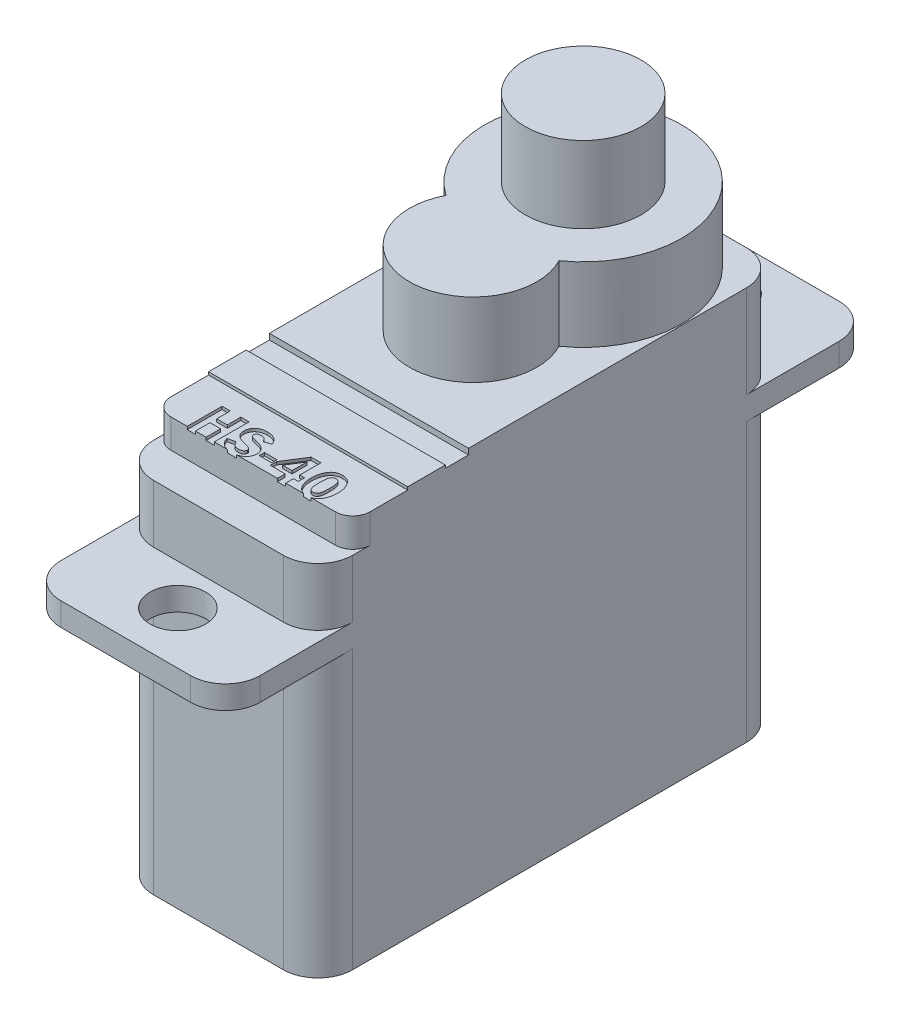
from build123d import *

# Parameters (mm, degrees)
SKETCH1_W            = 8.6
SKETCH1_H            = 28
BOSS_EXTRUDE1_DEPTH  = 1
SKETCH2_W            = 8.6
SKETCH2_H            = 20
BOSS_EXTRUDE2_DEPTH  = 4
M2_CLEARANCE_HOLE1_D = 2.4
SKETCH6_R            = 4.25
BOSS_EXTRUDE3_DEPTH  = 3.2
SKETCH7_R            = 2.5
BOSS_EXTRUDE4_DEPTH  = 3.3
SKETCH8_W            = 8.6
SKETCH8_H            = 20
BOSS_EXTRUDE5_DEPTH  = 12
SKETCH9_R            = 2.75
BOSS_EXTRUDE6_DEPTH  = 3.2
FILLET1_R            = 1.5
SKETCH10_W           = 8.6
SKETCH10_H           = 1.5
CUT_EXTRUDE1_DEPTH   = 1.5
FILLET2_R            = 0.75
SKETCH11_W           = 8.6
SKETCH11_H           = 5
CUT_EXTRUDE2_DEPTH   = 0.125
SKETCH12_W           = 8.6
SKETCH12_H           = 1
CUT_EXTRUDE3_DEPTH   = 0.125
SKETCH13_W           = 8.6
SKETCH13_H           = 2.375
CUT_EXTRUDE4_DEPTH   = 0.125
SKETCH14_W           = 0.541666667
SKETCH14_H           = 0.229166667
CUT_EXTRUDE5_DEPTH   = 0.125


with BuildPart() as part:
    # Sketch1 → Boss-Extrude1 (new body)
    with BuildSketch(Plane(origin=(0, 0, 0), x_dir=(1, 0, 0), z_dir=(0, 1, 0))):
        Rectangle(SKETCH1_W, SKETCH1_H)
    extrude(amount=BOSS_EXTRUDE1_DEPTH)

    # Sketch2 → Boss-Extrude2 (add)
    with BuildSketch(Plane(origin=(0, 1, 0), x_dir=(1, 0, 0), z_dir=(0, 1, 0))):
        Rectangle(SKETCH2_W, SKETCH2_H)
    extrude(amount=BOSS_EXTRUDE2_DEPTH)

    # M2 Clearance Hole1 (through all)
    with Locations(Plane(origin=(0, 1, 0), x_dir=(1, 0, 0), z_dir=(0, 1, 0))):
        with Locations((0, 11.75), (0, -11.75)):
            Hole(M2_CLEARANCE_HOLE1_D / 2)

    # Sketch6 → Boss-Extrude3 (add)
    with BuildSketch(Plane(origin=(0, 5, 0), x_dir=(1, 0, 0), z_dir=(0, 1, 0))):
        with Locations((0, 5.75)):
            Circle(SKETCH6_R)
    extrude(amount=BOSS_EXTRUDE3_DEPTH)

    # Sketch7 → Boss-Extrude4 (add)
    with BuildSketch(Plane(origin=(0, 8.2, 0), x_dir=(1, 0, 0), z_dir=(0, 1, 0))):
        with Locations((0, 5.75)):
            Circle(SKETCH7_R)
    extrude(amount=BOSS_EXTRUDE4_DEPTH)

    # Sketch8 → Boss-Extrude5 (add)
    with BuildSketch(Plane.XZ):
        Rectangle(SKETCH8_W, SKETCH8_H)
    extrude(amount=BOSS_EXTRUDE5_DEPTH)

    # Sketch9 → Boss-Extrude6 (add)
    with BuildSketch(Plane(origin=(0, 5, 0), x_dir=(1, 0, 0), z_dir=(0, 1, 0))):
        with Locations((0, 1)):
            Circle(SKETCH9_R)
    extrude(amount=BOSS_EXTRUDE6_DEPTH)

    # Fillet1
    fillet1_edges = [part.edges().sort_by_distance(p)[0] for p in [
        (4.3, 3, 10),
        (4.3, 3, -10),
        (-4.3, 3, -10),
        (-4.3, 3, 10),
        (-4.3, -6, -10),
        (4.3, -6, -10),
        (4.3, -6, 10),
        (-4.3, -6, 10),
        (4.3, 0.5, 14),
        (-4.3, 0.5, 14),
        (-4.3, 0.5, -14),
        (4.3, 0.5, -14),
    ]]
    fillet(fillet1_edges, radius=FILLET1_R)

    # Sketch10 → Cut-Extrude1 (cut)
    with BuildSketch(Plane(origin=(0, 5, 0), x_dir=(1, 0, 0), z_dir=(0, 1, 0))):
        with Locations((0, -9.25)):
            Rectangle(SKETCH10_W, SKETCH10_H)
    extrude(amount=-CUT_EXTRUDE1_DEPTH, mode=Mode.SUBTRACT)

    # Fillet2
    fillet2_edges = [part.edges().sort_by_distance(p)[0] for p in [
        (4.3, 4.25, 8.5),
        (-4.3, 4.25, 8.5),
    ]]
    fillet(fillet2_edges, radius=FILLET2_R)

    # Sketch11 → Cut-Extrude2 (cut)
    with BuildSketch(Plane(origin=(0, 5, 0), x_dir=(1, 0, 0), z_dir=(0, 1, 0))):
        with Locations((0, -6)):
            Rectangle(SKETCH11_W, SKETCH11_H)
    extrude(amount=-CUT_EXTRUDE2_DEPTH, mode=Mode.SUBTRACT)

    # Sketch12 → Cut-Extrude3 (cut)
    with BuildSketch(Plane(origin=(0, 4.875, 0), x_dir=(1, 0, 0), z_dir=(0, 1, 0))):
        with Locations((0, -4)):
            Rectangle(SKETCH12_W, SKETCH12_H)
    extrude(amount=-CUT_EXTRUDE3_DEPTH, mode=Mode.SUBTRACT)

    # Sketch13 → Cut-Extrude4 (cut)
    with BuildSketch(Plane(origin=(0, 4.875, 0), x_dir=(1, 0, 0), z_dir=(0, 1, 0))):
        with Locations((0, -7.3125)):
            Rectangle(SKETCH13_W, SKETCH13_H)
    extrude(amount=-CUT_EXTRUDE4_DEPTH, mode=Mode.SUBTRACT)

    # Sketch14 → Cut-Extrude5 (cut)
    with BuildSketch(Plane(origin=(0, 4.75, 0), x_dir=(1, 0, 0), z_dir=(0, 1, 0))):
        with BuildLine():
            add(Edge.make_bspline(
                [(2.330078125, -8.520833333), (2.308219564, -8.520304962), (2.265433565, -8.519270727), (2.203225824, -8.508320413), (2.144423844, -8.491752393), (2.089731145, -8.467291461), (2.038691562, -8.436441913), (1.991534512, -8.398586034), (1.947993742, -8.354027596), (1.908954081, -8.302799291), (1.873999266, -8.246704394), (1.843685658, -8.186487504), (1.817955169, -8.122778917), (1.796722315, -8.055545186), (1.7805313, -7.984536322), (1.76900483, -7.910022918), (1.761561122, -7.831965151), (1.760803351, -7.778771734), (1.760416667, -7.751627604)],
                knots=[0, 0, 0, 0, 6.5511e-05, 0.000128231, 0.000188908, 0.000248368, 0.000307377, 0.000367365, 0.000429287, 0.000493811, 0.000560199, 0.000627311, 0.000695799, 0.000766115, 0.000838604, 0.000914063, 0.000992192, 0.001073604, 0.001073604, 0.001073604, 0.001073604], degree=3))
            add(Edge.make_bspline(
                [(1.760416667, -7.751627604), (1.760836544, -7.724919667), (1.76166066, -7.67249865), (1.768659202, -7.595517959), (1.779924065, -7.521767295), (1.795890927, -7.451271178), (1.816269961, -7.383912596), (1.841854209, -7.320038), (1.871476837, -7.259212389), (1.905400033, -7.20199682), (1.943683462, -7.14970006), (1.986564509, -7.103871995), (2.034058097, -7.065335096), (2.085591995, -7.033690084), (2.141358833, -7.008826483), (2.201442265, -6.991829398), (2.265571183, -6.981155738), (2.309744046, -6.97984014), (2.332356771, -6.979166667)],
                knots=[0, 0, 0, 0, 8.0111e-05, 0.000157237, 0.000231682, 0.000303781, 0.000373904, 0.000442573, 0.000509977, 0.00057669, 0.000641861, 0.000704036, 0.000764433, 0.000824785, 0.000884972, 0.00094699, 0.001011637, 0.00107944, 0.00107944, 0.00107944, 0.00107944], degree=3))
            add(Edge.make_bspline(
                [(2.332356771, -6.979166667), (2.354861173, -6.979834872), (2.398711537, -6.981136887), (2.462413829, -6.991842432), (2.522203672, -7.008984056), (2.578038906, -7.033485839), (2.629426243, -7.0655473), (2.677177254, -7.103833274), (2.720383661, -7.149683029), (2.758961837, -7.202064971), (2.793528464, -7.259195767), (2.823902676, -7.319791736), (2.849251638, -7.383566238), (2.870173054, -7.450258741), (2.886388663, -7.520129927), (2.898079936, -7.593098772), (2.904985081, -7.669245056), (2.905822999, -7.721014356), (2.90625, -7.747395833)],
                knots=[0, 0, 0, 0, 6.7478e-05, 0.000131482, 0.000193188, 0.000253673, 0.000313747, 0.000374397, 0.000436796, 0.000502161, 0.00056921, 0.000636903, 0.000705269, 0.000774867, 0.000846404, 0.000920257, 0.000996411, 0.001075545, 0.001075545, 0.001075545, 0.001075545], degree=3))
            add(Edge.make_bspline(
                [(2.90625, -7.747395833), (2.905868982, -7.77432424), (2.905120898, -7.827195072), (2.897578402, -7.904677445), (2.886501105, -7.978917828), (2.87019626, -8.049775117), (2.849050353, -8.117243046), (2.823258501, -8.181361232), (2.79288513, -8.242108569), (2.758380045, -8.299175833), (2.71974187, -8.351426086), (2.676070087, -8.396821557), (2.628258598, -8.435041859), (2.576651019, -8.466956356), (2.520577333, -8.490868934), (2.460699905, -8.508236879), (2.396750714, -8.518845517), (2.352688862, -8.520159203), (2.330078125, -8.520833333)],
                knots=[0, 0, 0, 0, 8.0761e-05, 0.000158566, 0.000233332, 0.000305821, 0.000376448, 0.000445237, 0.000512931, 0.000579979, 0.000645084, 0.000707472, 0.000768376, 0.00082828, 0.000888933, 0.000950638, 0.001014964, 0.001082767, 0.001082767, 0.001082767, 0.001082767], degree=3))
        make_face()
        with BuildLine():
            add(Edge.make_bspline(
                [(2.333333333, -7.25), (2.32354542, -7.250276219), (2.304472194, -7.250814472), (2.277011516, -7.25602672), (2.251939493, -7.264944838), (2.229078195, -7.277049495), (2.208661195, -7.292950692), (2.190653743, -7.312302108), (2.175271693, -7.335283677), (2.161790211, -7.361700944), (2.150364938, -7.39263253), (2.14084143, -7.428410779), (2.132831136, -7.46943508), (2.126041837, -7.515486412), (2.12101348, -7.566879377), (2.117097853, -7.623429434), (2.114854089, -7.685311584), (2.114675965, -7.728296811), (2.114583333, -7.750651042)],
                knots=[0, 0, 0, 0, 2.9342e-05, 5.7177e-05, 8.3432e-05, 0.000108918, 0.000134442, 0.000160699, 0.000187875, 0.000217138, 0.000249484, 0.000286599, 0.000328095, 0.000374822, 0.000426193, 0.000482968, 0.000544859, 0.00061192, 0.00061192, 0.00061192, 0.00061192], degree=3))
            add(Edge.make_bspline(
                [(2.114583333, -7.750651042), (2.11463074, -7.773115867), (2.114721925, -7.816326313), (2.117560156, -7.878402147), (2.121184875, -7.935210233), (2.126846416, -7.986649993), (2.133242958, -8.032934294), (2.142199626, -8.07373984), (2.151945201, -8.109354113), (2.163743528, -8.139953442), (2.177534881, -8.166063656), (2.193277413, -8.188603571), (2.211225119, -8.207645935), (2.231445686, -8.223227354), (2.253722176, -8.235410741), (2.278175813, -8.243777979), (2.304553137, -8.249254824), (2.322887532, -8.249746211), (2.332356771, -8.25)],
                knots=[0, 0, 0, 0, 6.7386e-05, 0.000129615, 0.00018639, 0.000238119, 0.000284846, 0.000326474, 0.000363363, 0.000395522, 0.000424647, 0.000451742, 0.000477761, 0.000502828, 0.000528028, 0.00055356, 0.000580118, 0.000608485, 0.000608485, 0.000608485, 0.000608485], degree=3))
            add(Edge.make_bspline(
                [(2.332356771, -8.25), (2.341717654, -8.249743394), (2.359943813, -8.249243768), (2.386068423, -8.243766409), (2.410385219, -8.235664979), (2.432723921, -8.223944347), (2.452616339, -8.20828565), (2.47089655, -8.18985488), (2.486771451, -8.167777591), (2.500933581, -8.142215551), (2.513484726, -8.112493971), (2.523495608, -8.077660957), (2.532776386, -8.037946244), (2.539476995, -7.992951053), (2.545591922, -7.943049908), (2.549067865, -7.8879481), (2.551952609, -7.827829987), (2.552038654, -7.786028664), (2.552083333, -7.764322917)],
                knots=[0, 0, 0, 0, 2.8042e-05, 5.4599e-05, 7.9717e-05, 0.000104763, 0.000129831, 0.000155381, 0.000182402, 0.00021111, 0.000242912, 0.000278955, 0.000319701, 0.00036519, 0.000415338, 0.00047049, 0.000530767, 0.000595875, 0.000595875, 0.000595875, 0.000595875], degree=3))
            add(Edge.make_bspline(
                [(2.552083333, -7.764322917), (2.552034406, -7.740556415), (2.551940317, -7.69485203), (2.5491284, -7.629301577), (2.545455595, -7.569573472), (2.539983002, -7.515810667), (2.533023926, -7.467968683), (2.524259349, -7.425993915), (2.514193373, -7.389828087), (2.501962449, -7.35920801), (2.488109075, -7.333126345), (2.472173409, -7.310839975), (2.454033126, -7.292032927), (2.434072083, -7.27647844), (2.411805725, -7.264580362), (2.387520663, -7.256211075), (2.361135219, -7.250748179), (2.342801976, -7.250254812), (2.333333333, -7.25)],
                knots=[0, 0, 0, 0, 7.1292e-05, 0.000137099, 0.000196797, 0.000250792, 0.000299177, 0.00034176, 0.000379365, 0.000411644, 0.000440481, 0.000467765, 0.000493549, 0.000518616, 0.000543375, 0.000568907, 0.000595465, 0.000623832, 0.000623832, 0.000623832, 0.000623832], degree=3))
        make_face(mode=Mode.SUBTRACT)
        Polygon((1.40625, -6.979166667), (1.40625, -7.895833333), (1.614583333, -7.895833333), (1.614583333, -8.166666667), (1.40625, -8.166666667), (1.40625, -8.5), (1.052083333, -8.5), (1.052083333, -8.166666667), (0.40625, -8.166666667), (0.40625, -7.895833333), (0.982096354, -6.979166667), align=None)
        with BuildLine():
            Line((0.669596354, -7.895833333), (1.072916667, -7.895833333))
            Line((1.072916667, -7.895833333), (1.072916667, -7.38671875))
            add(Edge.make_bspline(
                [(1.072916667, -7.38671875), (1.072916667, -7.375868056), (1.072916667, -7.352105035), (1.072916667, -7.328342014), (1.072916667, -7.315429688)],
                knots=[0, 0, 0, 0, 3.2552e-05, 7.1289e-05, 7.1289e-05, 7.1289e-05, 7.1289e-05], degree=3))
            Line((1.072916667, -7.315429688), (1.072916667, -7.253580729))
            Line((1.072916667, -7.253580729), (0.669596354, -7.895833333))
        make_face(mode=Mode.SUBTRACT)
        with Locations((0.072916666, -7.927083334)):
            Rectangle(SKETCH14_W, SKETCH14_H)
        with BuildLine():
            Line((-0.34375, -7.336263021), (-0.635416667, -7.4375))
            add(Edge.make_bspline(
                [(-0.635416667, -7.4375), (-0.640635836, -7.422672729), (-0.65068363, -7.394127696), (-0.672113135, -7.355553348), (-0.697686652, -7.322874759), (-0.72745155, -7.295791526), (-0.761824631, -7.275182341), (-0.800246906, -7.260421945), (-0.842801882, -7.251506433), (-0.872568111, -7.250514795), (-0.888020833, -7.25)],
                knots=[0, 0, 0, 0, 4.7093e-05, 9.0661e-05, 0.000131689, 0.000171104, 0.000210685, 0.000251187, 0.000294089, 0.000340406, 0.000340406, 0.000340406, 0.000340406], degree=3))
            add(Edge.make_bspline(
                [(-0.888020833, -7.25), (-0.904099088, -7.250441553), (-0.934219522, -7.251268742), (-0.976412864, -7.257157029), (-1.012332924, -7.267678762), (-1.042104105, -7.282588882), (-1.065532489, -7.302172696), (-1.081953907, -7.326558985), (-1.092160424, -7.35513467), (-1.093204697, -7.375669999), (-1.09375, -7.386393229)],
                knots=[0, 0, 0, 0, 4.8231e-05, 9.0354e-05, 0.000127426, 0.000160039, 0.000189591, 0.000217941, 0.000247283, 0.00027935, 0.00027935, 0.00027935, 0.00027935], degree=3))
            add(Edge.make_bspline(
                [(-1.09375, -7.386393229), (-1.093403647, -7.395141266), (-1.092723077, -7.412330829), (-1.084590817, -7.436739174), (-1.072920081, -7.459485141), (-1.058566396, -7.476241334), (-1.043762337, -7.488430612), (-1.029447183, -7.497287387), (-1.012301779, -7.506208348), (-0.99209486, -7.514508487), (-0.968795965, -7.522605349), (-0.942632967, -7.530653621), (-0.913446343, -7.538556891), (-0.892923563, -7.54315938), (-0.882161458, -7.545572917)],
                knots=[0, 0, 0, 0, 2.6141e-05, 5.1366e-05, 7.6412e-05, 0.000102505, 0.000116843, 0.00013382, 0.000152893, 0.000174778, 0.000199281, 0.000226875, 0.000256881, 0.000289966, 0.000289966, 0.000289966, 0.000289966], degree=3))
            add(Edge.make_bspline(
                [(-0.882161458, -7.545572917), (-0.864024172, -7.549625903), (-0.828883496, -7.557478494), (-0.77816703, -7.570020728), (-0.730926205, -7.581744841), (-0.687718467, -7.594263352), (-0.648323383, -7.606291974), (-0.612569479, -7.617814629), (-0.580794612, -7.630039984), (-0.543051457, -7.645193069), (-0.500101957, -7.668216943), (-0.453284257, -7.702597958), (-0.410787663, -7.744327521), (-0.379568969, -7.784289292), (-0.357200316, -7.818966831), (-0.342379906, -7.846117394), (-0.330164202, -7.87420686), (-0.319529827, -7.902789259), (-0.311727261, -7.932355851), (-0.306373018, -7.96263815), (-0.302440516, -7.993713217), (-0.302203378, -8.014744215), (-0.302083333, -8.025390625)],
                knots=[0, 0, 0, 0, 5.5752e-05, 0.000108018, 0.000156731, 0.000201757, 0.000242946, 0.000280313, 0.000314412, 0.000345061, 0.000402295, 0.000460045, 0.000518745, 0.000580414, 0.000611747, 0.00064248, 0.000673086, 0.000703567, 0.000733888, 0.000764663, 0.000795794, 0.00082771, 0.00082771, 0.00082771, 0.00082771], degree=3))
            add(Edge.make_bspline(
                [(-0.302083333, -8.025390625), (-0.302632395, -8.041906506), (-0.30371763, -8.074550547), (-0.310898411, -8.122746513), (-0.323430264, -8.169040356), (-0.340430758, -8.213876813), (-0.362680862, -8.256839288), (-0.389839703, -8.298092447), (-0.422213899, -8.337274719), (-0.458656072, -8.375032196), (-0.500167874, -8.409657489), (-0.546975986, -8.43924278), (-0.597971277, -8.464962161), (-0.654152924, -8.485173084), (-0.71485187, -8.501624865), (-0.780488528, -8.512651934), (-0.850650657, -8.519637792), (-0.89896229, -8.520427086), (-0.923828125, -8.520833333)],
                knots=[0, 0, 0, 0, 4.9548e-05, 9.7932e-05, 0.000145783, 0.000193179, 0.000241514, 0.000290629, 0.000341063, 0.000393778, 0.000447877, 0.000502778, 0.000559554, 0.000618875, 0.000681572, 0.000747986, 0.000818306, 0.000892885, 0.000892885, 0.000892885, 0.000892885], degree=3))
            add(Edge.make_bspline(
                [(-0.923828125, -8.520833333), (-0.942722913, -8.520570253), (-0.979935933, -8.52005212), (-1.034583987, -8.514490385), (-1.087182377, -8.506657063), (-1.137583006, -8.494883366), (-1.185682712, -8.479470677), (-1.231967119, -8.461325352), (-1.275887429, -8.439415241), (-1.317608832, -8.414471833), (-1.356473359, -8.386113683), (-1.392090497, -8.354473357), (-1.424321774, -8.319461138), (-1.452371735, -8.280830047), (-1.47792664, -8.239604027), (-1.499153144, -8.194704132), (-1.517707366, -8.146801645), (-1.526679669, -8.113163378), (-1.53125, -8.096028646)],
                knots=[0, 0, 0, 0, 5.6664e-05, 0.000111599, 0.000164636, 0.000216118, 0.000266666, 0.000316052, 0.000365111, 0.000413736, 0.000461721, 0.000509219, 0.00055645, 0.000604173, 0.000652242, 0.000701743, 0.000752949, 0.000806114, 0.000806114, 0.000806114, 0.000806114], degree=3))
            Line((-1.53125, -8.096028646), (-1.197916667, -8.020833333))
            add(Edge.make_bspline(
                [(-1.197916667, -8.020833333), (-1.192961369, -8.038939271), (-1.183437792, -8.073737039), (-1.160292075, -8.121026288), (-1.131043643, -8.161140274), (-1.095544401, -8.194130591), (-1.053652474, -8.219545614), (-1.005712919, -8.237319412), (-0.951874999, -8.248215247), (-0.914008989, -8.249387127), (-0.894205729, -8.25)],
                knots=[0, 0, 0, 0, 5.6218e-05, 0.000108045, 0.000156941, 0.000204393, 0.000252461, 0.000302943, 0.00035708, 0.000416433, 0.000416433, 0.000416433, 0.000416433], degree=3))
            add(Edge.make_bspline(
                [(-0.894205729, -8.25), (-0.884543138, -8.249912459), (-0.865731497, -8.249742028), (-0.838567504, -8.247362209), (-0.81320201, -8.2438887), (-0.789765552, -8.238757173), (-0.768230982, -8.231891438), (-0.748608895, -8.22376489), (-0.730783056, -8.214392125), (-0.710491547, -8.199823928), (-0.689220712, -8.17953712), (-0.670029765, -8.152120524), (-0.658163187, -8.121898098), (-0.656890822, -8.100796844), (-0.65625, -8.090169271)],
                knots=[0, 0, 0, 0, 2.8979e-05, 5.6417e-05, 8.1737e-05, 0.000105746, 0.000128292, 0.000149451, 0.000169403, 0.000188551, 0.000224235, 0.000257011, 0.000288329, 0.000320107, 0.000320107, 0.000320107, 0.000320107], degree=3))
            add(Edge.make_bspline(
                [(-0.65625, -8.090169271), (-0.656797054, -8.079663738), (-0.657856913, -8.059310406), (-0.668386795, -8.030682031), (-0.686033791, -8.006111676), (-0.706213762, -7.989373682), (-0.725972639, -7.977516819), (-0.744141674, -7.968459085), (-0.765515766, -7.959900243), (-0.789660822, -7.950512105), (-0.817225745, -7.941942401), (-0.84794247, -7.933670487), (-0.881466578, -7.924617726), (-0.905032801, -7.919391212), (-0.917317708, -7.916666667)],
                knots=[0, 0, 0, 0, 3.1419e-05, 6.0871e-05, 9.0047e-05, 0.000121224, 0.000138753, 0.000159134, 0.000182046, 0.000207801, 0.000236833, 0.000268581, 0.000303242, 0.000340987, 0.000340987, 0.000340987, 0.000340987], degree=3))
            add(Edge.make_bspline(
                [(-0.917317708, -7.916666667), (-0.940379965, -7.911471255), (-0.984996141, -7.901420225), (-1.048647566, -7.883127176), (-1.107559766, -7.865045336), (-1.160953211, -7.844591604), (-1.209789678, -7.823740184), (-1.253155309, -7.800950864), (-1.29186326, -7.777557859), (-1.325396463, -7.752322154), (-1.354794129, -7.724993491), (-1.379436034, -7.694392581), (-1.401014262, -7.661305436), (-1.418102474, -7.624979817), (-1.431662894, -7.585822817), (-1.440774909, -7.543733494), (-1.446928924, -7.498769669), (-1.447580609, -7.467795544), (-1.447916667, -7.451822917)],
                knots=[0, 0, 0, 0, 7.0904e-05, 0.00013717, 0.000198632, 0.000255705, 0.000308622, 0.000357834, 0.000402554, 0.000444156, 0.000483533, 0.00052263, 0.000561727, 0.000601768, 0.000642739, 0.00068578, 0.000730759, 0.000778651, 0.000778651, 0.000778651, 0.000778651], degree=3))
            add(Edge.make_bspline(
                [(-1.447916667, -7.451822917), (-1.447491762, -7.435523112), (-1.446655082, -7.403427168), (-1.439648716, -7.356286935), (-1.428161227, -7.311194397), (-1.412653635, -7.267802769), (-1.391814873, -7.226761831), (-1.367064046, -7.18726439), (-1.337114657, -7.150271117), (-1.303514364, -7.115105744), (-1.265691724, -7.083191928), (-1.224387858, -7.05516784), (-1.179696166, -7.031601989), (-1.131909613, -7.012353937), (-1.080872206, -6.997425012), (-1.026639047, -6.986661751), (-0.969105921, -6.980576332), (-0.929701575, -6.979644347), (-0.909505208, -6.979166667)],
                knots=[0, 0, 0, 0, 4.8881e-05, 9.6252e-05, 0.000142596, 0.000188318, 0.000234175, 0.000280412, 0.000327895, 0.000376701, 0.000426133, 0.000476061, 0.000526153, 0.000577413, 0.000630356, 0.00068545, 0.000743075, 0.000803664, 0.000803664, 0.000803664, 0.000803664], degree=3))
            add(Edge.make_bspline(
                [(-0.909505208, -6.979166667), (-0.891593265, -6.979384793), (-0.856476374, -6.979812436), (-0.805047034, -6.984096413), (-0.756137514, -6.991243799), (-0.709708512, -7.001018637), (-0.66558958, -7.013307133), (-0.623846964, -7.028543721), (-0.584703176, -7.046849679), (-0.547957422, -7.067775584), (-0.513646687, -7.091515888), (-0.482040068, -7.118443446), (-0.452610042, -7.147713926), (-0.425791354, -7.179915054), (-0.401242738, -7.214779005), (-0.379622411, -7.252756456), (-0.359747806, -7.293171297), (-0.34914622, -7.321727753), (-0.34375, -7.336263021)],
                knots=[0, 0, 0, 0, 5.3727e-05, 0.000105333, 0.000154683, 0.000201928, 0.000247581, 0.000291967, 0.000335074, 0.000377065, 0.000418693, 0.00046004, 0.000501472, 0.000543067, 0.000585602, 0.000629209, 0.00067405, 0.000720536, 0.000720536, 0.000720536, 0.000720536], degree=3))
        make_face()
        Polygon((-1.677083333, -7), (-1.677083333, -8.5), (-2.03125, -8.5), (-2.03125, -7.875), (-2.489583333, -7.875), (-2.489583333, -8.5), (-2.84375, -8.5), (-2.84375, -7), (-2.489583333, -7), (-2.489583333, -7.583333333), (-2.03125, -7.583333333), (-2.03125, -7), align=None)
    extrude(amount=-CUT_EXTRUDE5_DEPTH, mode=Mode.SUBTRACT)


solid = part.part
